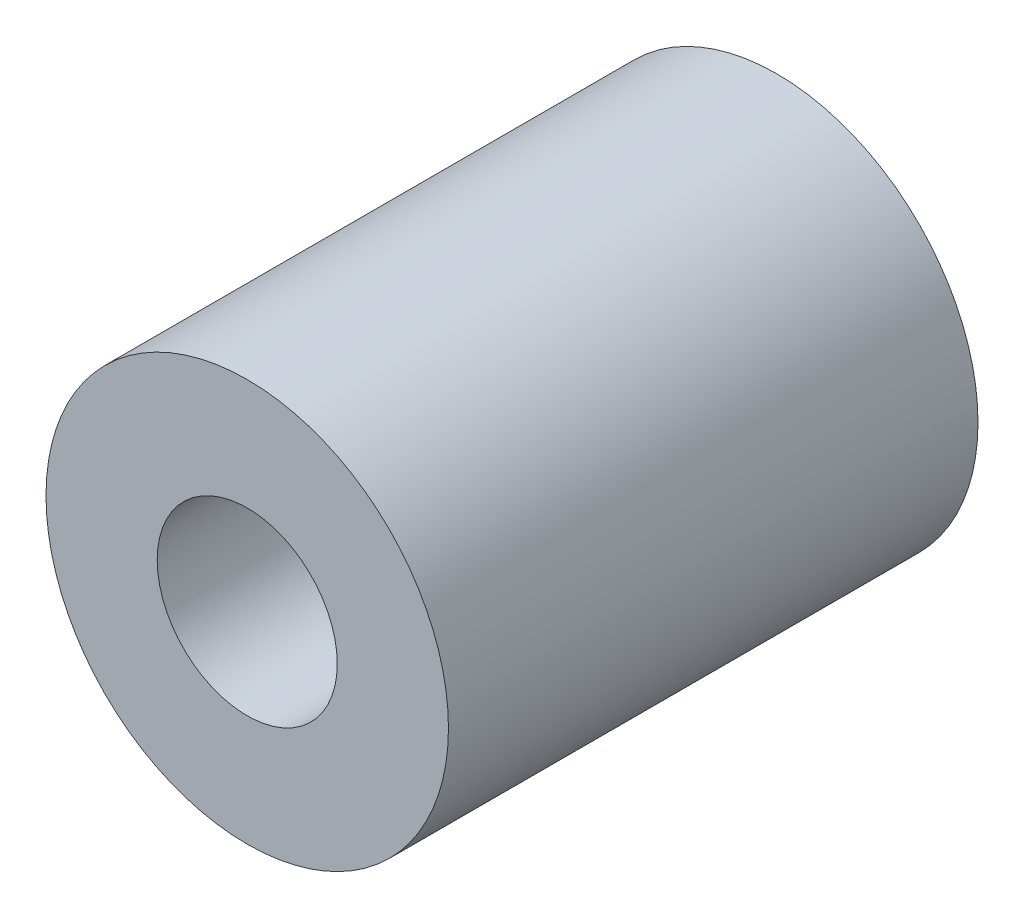
from build123d import *

# Parameters (mm, degrees)
SKETCH1_R           = 9.5
BOSS_EXTRUDE1_DEPTH = 25
SKETCH1_3_R         = 9.5
BOSS_EXTRUDE2_DEPTH = 25
SKETCH2_R           = 4.25
CUT_EXTRUDE1_DEPTH  = 25


with BuildPart() as part:
    # Sketch1 → Boss-Extrude1 (new body)
    with BuildSketch(Plane.XY):
        Circle(SKETCH1_R)
    extrude(amount=BOSS_EXTRUDE1_DEPTH)

    # Sketch1_3 → Boss-Extrude2 (add)
    with BuildSketch(Plane.XY):
        Circle(SKETCH1_3_R)
    extrude(amount=BOSS_EXTRUDE2_DEPTH)

    # Sketch2 → Cut-Extrude1 (cut)
    with BuildSketch(Plane.XY.offset(25)):
        Circle(SKETCH2_R)
    extrude(amount=-CUT_EXTRUDE1_DEPTH, mode=Mode.SUBTRACT)


solid = part.part
